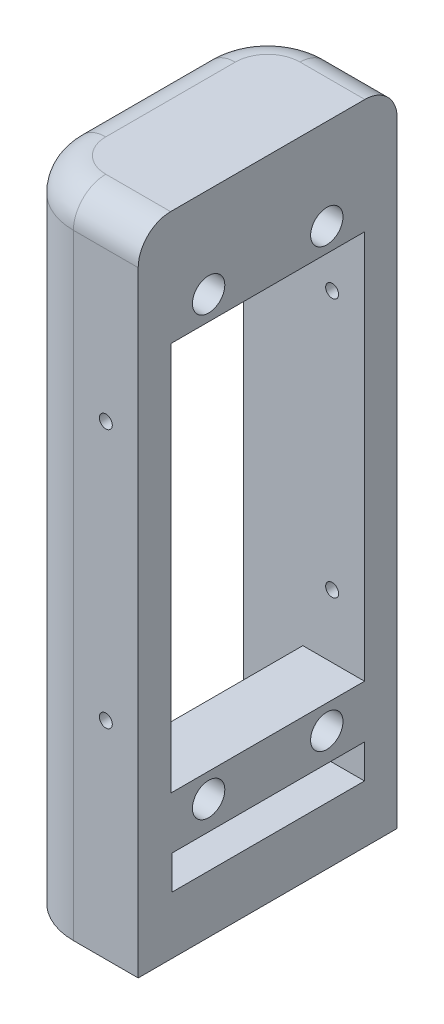
from build123d import *
from build123d.topology import SkipClean

# Parameters (mm, degrees)
BOSS_EXTRUDE1_DEPTH = 100
SKETCH11_W          = 29.1
SKETCH11_H          = 75.5
CUT_EXTRUDE1_DEPTH  = 11.2
SKETCH13_R          = 4.4
CUT_EXTRUDE5_DEPTH  = 22.2
FILLET1_R           = 5
SKETCH14_W          = 29.1
SKETCH14_H          = 8.115
SKETCH14_R          = 2.75
SKETCH14_H_2        = 8.075
BOSS_EXTRUDE2_DEPTH = 0.72
SKETCH15_R          = 2.75
SKETCH15_R_2        = 1.25
BOSS_EXTRUDE3_DEPTH = 9.52
SKETCH16_R          = 2.5
CUT_EXTRUDE6_DEPTH  = 4
SKETCH17_W          = 29.764027379
SKETCH17_H          = 76.3
SKETCH17_W_2        = 28.964027379
SKETCH17_H_2        = 75.5
CUT_EXTRUDE7_DEPTH  = 44
SKETCH18_W          = 29.9
SKETCH18_H          = 60.11
SKETCH18_W_2        = 29.1
SKETCH18_H_2        = 59.31
CUT_EXTRUDE8_DEPTH  = 44
SKETCH19_W          = 29.764027379
SKETCH19_H          = 5.226630125
CUT_EXTRUDE9_DEPTH  = 44
SKETCH21_R          = 1
CUT_EXTRUDE10_DEPTH = 122.5
SKETCH22_R          = 1
CUT_EXTRUDE11_DEPTH = 10.5


with BuildPart() as part:
    # Sketch1 → Boss-Extrude1 (new body)
    with BuildSketch(Plane(origin=(0, 0, 0), x_dir=(1, 0, 0), z_dir=(0, 1, 0))):
        with BuildLine():
            Line((-4.0452326, 19.590813971), (5.9547674, 19.590813971))
            Line((5.9547674, 19.590813971), (5.9547674, -0.409186029))
            Line((5.9547674, -0.409186029), (5.9547674, -20.409186029))
            Line((5.9547674, -20.409186029), (-4.0452326, -20.409186029))
            ThreePointArc((-4.0452326, -20.409186029), (-11.116300412, -17.48025384), (-14.0452326, -10.409186029))
            Line((-14.0452326, -10.409186029), (-14.0452326, 9.590813971))
            ThreePointArc((-14.0452326, 9.590813971), (-11.116300412, 16.661881783), (-4.0452326, 19.590813971))
        make_face()
    extrude(amount=BOSS_EXTRUDE1_DEPTH)

    # Sketch11 → Cut-Extrude1 (cut)
    with BuildSketch(Plane.ZY.offset(14.0452326)):
        with Locations((0.409186029, 52.25)):
            Rectangle(SKETCH11_W, SKETCH11_H)
    extrude(amount=-CUT_EXTRUDE1_DEPTH, mode=Mode.SUBTRACT)

    # Sketch13 → Cut-Extrude5 (cut)
    with BuildSketch(Plane.ZY.offset(2.8452326)):
        with BuildLine():
            ThreePointArc((12.284186029, 86), (11.93014617, 87.349768499), (10.959186029, 88.351993835))
            ThreePointArc((10.959186029, 88.351993835), (9.534186029, 88.75), (8.109186029, 88.351993835))
            ThreePointArc((8.109186029, 88.351993835), (8.18441753, 83.604039858), (12.284186029, 86))
        make_face()
        with BuildLine():
            ThreePointArc((-5.965813971, 86), (-6.31985383, 87.349768499), (-7.290813971, 88.351993835))
            ThreePointArc((-7.290813971, 88.351993835), (-8.715813971, 88.75), (-10.140813971, 88.351993835))
            ThreePointArc((-10.140813971, 88.351993835), (-10.06558247, 83.604039858), (-5.965813971, 86))
        make_face()
        Polygon((4.229186029, 22.615), (14.959186029, 22.615), (14.959186029, 38.515), (14.959186029, 80.015), (14.959186029, 81.925), (4.229186029, 81.925), (2.559186029, 81.925), (-1.740813971, 81.925), (-3.410813971, 81.925), (-14.140813971, 81.925), (-14.140813971, 80.015), (-14.140813971, 38.515), (-14.140813971, 22.615), (-3.410813971, 22.615), (-1.740813971, 22.615), (2.559186029, 22.615), align=None)
        Polygon((12.984186029, 43.815), (12.984186029, 38.515), (12.984186029, 24.115), (-12.165813971, 24.115), (-12.165813971, 38.515), (-12.165813971, 43.815), align=None, mode=Mode.SUBTRACT)
        with BuildLine():
            ThreePointArc((7.989888554, 59.032180934), (6.768483101, 52.645011162), (6.359186029, 46.155))
            Line((6.359186029, 46.155), (-5.540813971, 46.155))
            ThreePointArc((-5.540813971, 46.155), (-5.950111044, 52.645011162), (-7.171516497, 59.032180934))
            ThreePointArc((-7.171516497, 59.032180934), (-7.78796768, 60.755318567), (-8.708121769, 62.337257826))
            ThreePointArc((-8.708121769, 62.337257826), (-9.536012183, 73.954242881), (0.409186029, 80.015))
            ThreePointArc((0.409186029, 80.015), (10.35438424, 73.954242881), (9.526493826, 62.337257826))
            ThreePointArc((9.526493826, 62.337257826), (8.606339737, 60.755318567), (7.989888554, 59.032180934))
        make_face(mode=Mode.SUBTRACT)
        with BuildLine():
            ThreePointArc((9.526493826, 62.337257826), (10.35438424, 73.954242881), (0.409186029, 80.015))
            ThreePointArc((0.409186029, 80.015), (-9.536012183, 73.954242881), (-8.708121769, 62.337257826))
            ThreePointArc((-8.708121769, 62.337257826), (-7.78796768, 60.755318567), (-7.171516497, 59.032180934))
            ThreePointArc((-7.171516497, 59.032180934), (-5.950111044, 52.645011162), (-5.540813971, 46.155))
            Line((-5.540813971, 46.155), (6.359186029, 46.155))
            ThreePointArc((6.359186029, 46.155), (6.768483101, 52.645011162), (7.989888554, 59.032180934))
            ThreePointArc((7.989888554, 59.032180934), (8.606339737, 60.755318567), (9.526493826, 62.337257826))
        make_face()
        with Locations((0.409186029, 68.825)):
            Circle(SKETCH13_R, mode=Mode.SUBTRACT)
        with Locations((0.409186029, 68.825)):
            Circle(SKETCH13_R)
        Polygon((12.984186029, 43.815), (12.984186029, 38.515), (12.984186029, 24.115), (-12.165813971, 24.115), (-12.165813971, 38.515), (-12.165813971, 43.815), align=None)
        with BuildLine():
            ThreePointArc((8.109186029, 16.148006165), (9.534186029, 15.75), (10.959186029, 16.148006165))
            ThreePointArc((10.959186029, 16.148006165), (11.93014617, 17.150231501), (12.284186029, 18.5))
            ThreePointArc((12.284186029, 18.5), (8.18441753, 20.895960142), (8.109186029, 16.148006165))
        make_face()
        with BuildLine():
            ThreePointArc((-10.140813971, 16.148006165), (-8.715813971, 15.75), (-7.290813971, 16.148006165))
            ThreePointArc((-7.290813971, 16.148006165), (-6.31985383, 17.150231501), (-5.965813971, 18.5))
            ThreePointArc((-5.965813971, 18.5), (-10.06558247, 20.895960142), (-10.140813971, 16.148006165))
        make_face()
    extrude(amount=-CUT_EXTRUDE5_DEPTH, mode=Mode.SUBTRACT)

    # Fillet1
    fillet1_edges = [part.edges().sort_by_distance(p)[0] for p in [
        (-11.116300412, 100, -16.661881783),
        (-14.0452326, 100, 0.409186029),
        (-11.116300412, 100, 17.48025384),
        (0.9547674, 100, 20.409186029),
        (0.9547674, 100, -19.590813971),
    ]]
    fillet(fillet1_edges, radius=FILLET1_R)

    # Sketch14 → Boss-Extrude2 (add)
    with SkipClean():  # the faces are left unmerged after this step: merging them gives an invalid solid
        with BuildSketch(Plane.ZY.offset(2.8452326)):
            with Locations((0.409186029, 18.5575)):
                Rectangle(SKETCH14_W, SKETCH14_H)
            with Locations((9.534186029, 18.5)):
                Circle(SKETCH14_R, mode=Mode.SUBTRACT)
            with Locations((-8.715813971, 18.5)):
                Circle(SKETCH14_R, mode=Mode.SUBTRACT)
            with Locations((0.409186029, 85.9625)):
                Rectangle(SKETCH14_W, SKETCH14_H_2)
            with Locations((9.534186029, 86)):
                Circle(SKETCH14_R, mode=Mode.SUBTRACT)
            with Locations((-8.715813971, 86)):
                Circle(SKETCH14_R, mode=Mode.SUBTRACT)
        extrude(amount=BOSS_EXTRUDE2_DEPTH)

    # Sketch15 → Boss-Extrude3 (add)
    with BuildSketch(Plane(origin=(5.9547674, 0, 0), x_dir=(0, 0, -1), z_dir=(1, 0, 0))):
        with Locations((8.715813971, 18.5)):
            Circle(SKETCH15_R)
        with Locations((8.715813971, 18.5)):
            Circle(SKETCH15_R_2, mode=Mode.SUBTRACT)
        with Locations((-9.534186029, 18.5)):
            Circle(SKETCH15_R)
        with Locations((-9.534186029, 18.5)):
            Circle(SKETCH15_R_2, mode=Mode.SUBTRACT)
        with Locations((8.715813971, 86)):
            Circle(SKETCH15_R)
        with Locations((8.715813971, 86)):
            Circle(SKETCH15_R_2, mode=Mode.SUBTRACT)
        with Locations((-9.534186029, 86)):
            Circle(SKETCH15_R)
        with Locations((-9.534186029, 86)):
            Circle(SKETCH15_R_2, mode=Mode.SUBTRACT)
    extrude(amount=-BOSS_EXTRUDE3_DEPTH)

    # Sketch16 → Cut-Extrude6 (cut)
    with BuildSketch(Plane(origin=(5.9547674, 0, 0), x_dir=(0, 0, -1), z_dir=(1, 0, 0))):
        with Locations((-9.534186029, 18.5)):
            Circle(SKETCH16_R)
        with Locations((8.715813971, 18.5)):
            Circle(SKETCH16_R)
        with Locations((-9.534186029, 86)):
            Circle(SKETCH16_R)
        with Locations((8.715813971, 86)):
            Circle(SKETCH16_R)
    extrude(amount=-CUT_EXTRUDE6_DEPTH, mode=Mode.SUBTRACT)

    # Sketch17 → Cut-Extrude7 (cut)
    with BuildSketch(Plane.ZY.offset(3.5652326)):
        with Locations((0.341199719, 52.25)):
            Rectangle(SKETCH17_W, SKETCH17_H)
        with Locations((0.341199719, 52.25)):
            Rectangle(SKETCH17_W_2, SKETCH17_H_2, mode=Mode.SUBTRACT)
    extrude(amount=CUT_EXTRUDE7_DEPTH, mode=Mode.SUBTRACT)

    # Sketch18 → Cut-Extrude8 (cut)
    with BuildSketch(Plane.ZY.offset(3.5652326)):
        with Locations((0.409186029, 52.27)):
            Rectangle(SKETCH18_W, SKETCH18_H)
        with Locations((0.409186029, 52.27)):
            Rectangle(SKETCH18_W_2, SKETCH18_H_2, mode=Mode.SUBTRACT)
    extrude(amount=-CUT_EXTRUDE8_DEPTH, mode=Mode.SUBTRACT)

    # Sketch19 → Cut-Extrude9 (cut)
    with BuildSketch(Plane.ZY.offset(14.0452326)):
        with Locations((0.341199719, 11.486684938)):
            Rectangle(SKETCH19_W, SKETCH19_H)
    extrude(amount=-CUT_EXTRUDE9_DEPTH, mode=Mode.SUBTRACT)

    # Sketch21 → Cut-Extrude10 (cut)
    with BuildSketch(Plane(origin=(0, 0, -19.590813971), x_dir=(-1, 0, 0), z_dir=(0, 0, -1))):
        with Locations((-0.9547674, 71.936684938)):
            Circle(SKETCH21_R)
        with Locations((-0.9547674, 31.936684938)):
            Circle(SKETCH21_R)
    extrude(amount=-CUT_EXTRUDE10_DEPTH, mode=Mode.SUBTRACT)

    # Sketch22 → Cut-Extrude11 (cut)
    with BuildSketch(Plane.XZ):
        with Locations(Location((-4.0452326, -9.590813971, 0), (0, 0, 270))):
            Circle(SKETCH22_R)
        with Locations(Location((-4.0452326, 10.409186029, 0), (0, 0, 270))):
            Circle(SKETCH22_R)
    extrude(amount=-CUT_EXTRUDE11_DEPTH, mode=Mode.SUBTRACT)


solid = part.part
